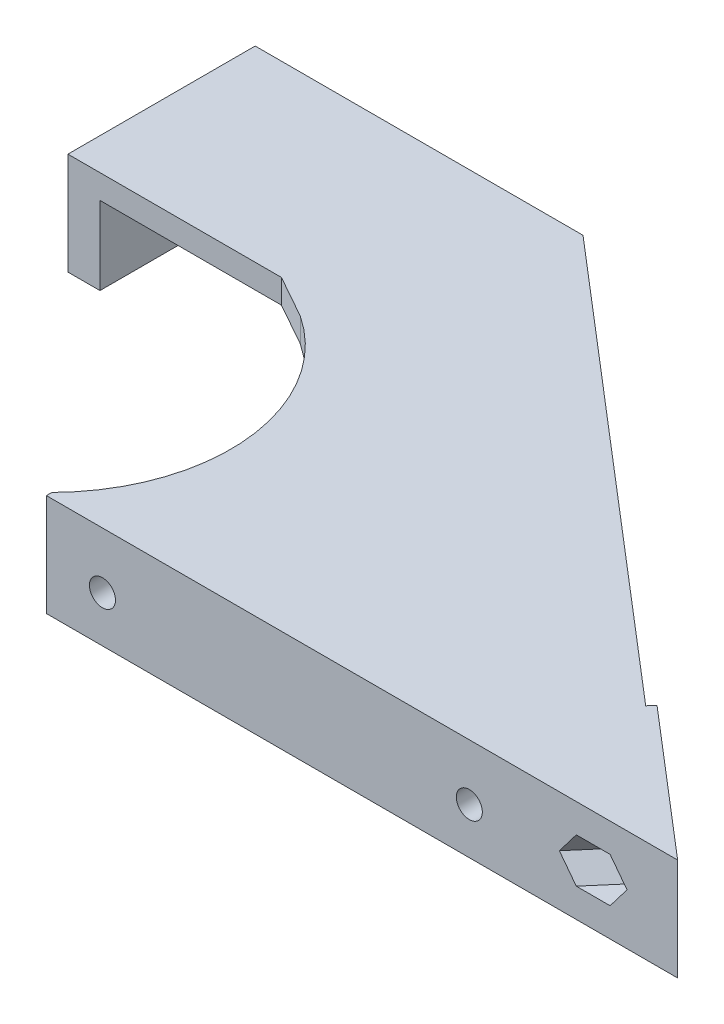
from build123d import *

# Parameters (mm, degrees)
SALIENTE_EXTRUIR1_DEPTH     = 12.75
CORTAR_EXTRUIR1_REACH       = 31.62
CROQUIS2_R                  = 1.625
CROQUIS3_R                  = 22.5
CORTAR_EXTRUIR2_DEPTH       = 13.75
SALIENTE_EXTRUIR2_DEPTH     = 3
SALIENTE_EXTRUIR3_DEPTH     = 9.75
CROQUIS6_R                  = 1.625
CORTAR_EXTRUIR3_DEPTH       = 10
CORTAR_EXTRUIR4_START       = -2
CORTAR_EXTRUIR4_DEPTH       = 10
CORTAR_EXTRUIR5_START       = -2
CORTAR_EXTRUIR5_DEPTH       = 10
CORTAR_EXTRUIR6_DEPTH       = 2
CORTAR_EXTRUIR7_REACH       = 37.25
CROQUIS10_R                 = 1.625
CORTAR_EXTRUIR8_DEPTH       = 2
CROQUIS12_W                 = 92.508691999
CROQUIS12_H                 = 24.255818813
CORTAR_EXTRUIR9_DEPTH       = 1
CORTAR_EXTRUIR9_DEPTH_BACK  = 36.25
SALIENTE_EXTRUIR4_DEPTH     = 12.75
CORTAR_EXTRUIR10_START      = -9.75
CORTAR_EXTRUIR10_DEPTH      = 9.75
CROQUIS16_W                 = 76.692813467
CROQUIS16_H                 = 12.75
CORTAR_EXTRUIR11_DEPTH      = 1
CROQUIS17_W                 = 40.657498706
CROQUIS17_H                 = 22.934549925
CORTAR_EXTRUIR12_DEPTH      = 1
CORTAR_EXTRUIR12_DEPTH_BACK = 13.75
SALIENTE_EXTRUIR5_REACH     = 14.75
CROQUIS18_W                 = 34.9120451
CROQUIS18_H                 = 3.951156815
CROQUIS20_R                 = 1.625
CORTAR_EXTRUIR14_DEPTH      = 10
CORTAR_EXTRUIR15_DEPTH      = 2
CROQUIS22_R                 = 1.625
CORTAR_EXTRUIR16_DEPTH      = 10
CORTAR_EXTRUIR17_DEPTH      = 2
SALIENTE_EXTRUIR6_DEPTH     = 12.75
CORTAR_EXTRUIR18_DEPTH      = 2
CROQUIS28_R                 = 1.625
SALIENTE_EXTRUIR7_DEPTH     = 1
CORTAR_EXTRUIR19_REACH      = 110.346
CROQUIS29_R                 = 1.993280097
CORTAR_EXTRUIR20_DEPTH      = 2
SALIENTE_EXTRUIR8_DEPTH     = 12.75
SALIENTE_EXTRUIR9_START     = -2.904645
SALIENTE_EXTRUIR9_DEPTH     = 5
SALIENTE_EXTRUIR10_REACH    = 76.413
CORTAR_EXTRUIR21_START      = -9.75
CORTAR_EXTRUIR21_DEPTH      = 9.75
CROQUIS36_R                 = 1.625
CORTAR_EXTRUIR22_DEPTH      = 15
CORTAR_EXTRUIR23_DEPTH      = 2
CORTAR_EXTRUIR24_START      = -2
CORTAR_EXTRUIR24_DEPTH      = 73.413335578
CROQUIS19_W                 = 120.448667976
CROQUIS19_H                 = 32.886651308
CORTAR_EXTRUIR13_DEPTH      = 1
CORTAR_EXTRUIR13_DEPTH_BACK = 62.623336743


with BuildPart() as part:
    # Croquis1 → Saliente-Extruir1 (new body)
    with BuildSketch(Plane(origin=(0, 0, 0), x_dir=(1, 0, 0), z_dir=(0, 1, 0))):
        Polygon((0, 0), (72.78319995, 0), (38.224450787, 29.62043043), (35.621353918, 26.5833452), (60.803074847, 5), (0, 5), align=None)
    extrude(amount=SALIENTE_EXTRUIR1_DEPTH)

    # Croquis2 → Cortar-Extruir1 (cut, up to next)
    with BuildSketch(Plane.XY, mode=Mode.PRIVATE) as cortar_extruir1_sk1:
        with Locations((52.78319995, 5.75)):
            Circle(CROQUIS2_R)
    cortar_extruir1_tool1 = extrude(cortar_extruir1_sk1.sketch, amount=-CORTAR_EXTRUIR1_REACH, mode=Mode.PRIVATE) & part.part
    add(cortar_extruir1_tool1.solids().sort_by_distance((52.7832, 5.75, 0))[0], mode=Mode.SUBTRACT)
    # Croquis2 → Cortar-Extruir1 (cut, up to next)
    with BuildSketch(Plane.XY, mode=Mode.PRIVATE) as cortar_extruir1_sk2:
        with Locations((6.99999995, 5.75)):
            Circle(CROQUIS2_R)
    cortar_extruir1_tool2 = extrude(cortar_extruir1_sk2.sketch, amount=-CORTAR_EXTRUIR1_REACH, mode=Mode.PRIVATE) & part.part
    add(cortar_extruir1_tool2.solids().sort_by_distance((7, 5.75, 0))[0], mode=Mode.SUBTRACT)

    # Croquis3 → Cortar-Extruir2 (cut, through all)
    with BuildSketch(Plane(origin=(0, 12.75, 0), x_dir=(1, 0, 0), z_dir=(0, 1, 0))):
        with Locations((-16, 16.5)):
            Circle(CROQUIS3_R)
    extrude(amount=-CORTAR_EXTRUIR2_DEPTH, mode=Mode.SUBTRACT)

    # Croquis4 → Saliente-Extruir2 (add)
    with BuildSketch(Plane(origin=(0, 12.75, 0), x_dir=(1, 0, 0), z_dir=(0, 1, 0))):
        with BuildLine():
            Line((38.224450787, 29.62043043), (31.656319269, 35.25))
            Line((31.656319269, 35.25), (-3.562657036, 35.25))
            ThreePointArc((-3.562657036, 35.25), (5.936291456, 21.504909307), (3.339079606, 5))
            Line((3.339079606, 5), (60.803074847, 5))
            Line((60.803074847, 5), (35.621353918, 26.5833452))
            Line((35.621353918, 26.5833452), (38.224450787, 29.62043043))
        make_face()
    extrude(amount=-SALIENTE_EXTRUIR2_DEPTH)

    # Croquis5 → Saliente-Extruir3 (add)
    with BuildSketch(Plane.XZ.offset(-9.75)):
        with BuildLine():
            Line((-3.562657036, -35.25), (31.656319269, -35.25))
            Line((31.656319269, -35.25), (38.224450787, -29.62043043))
            Line((38.224450787, -29.62043043), (35.621353918, -26.5833452))
            Line((35.621353918, -26.5833452), (30.17667434, -31.25))
            Line((30.17667434, -31.25), (0.990806338, -31.25))
            ThreePointArc((0.990806338, -31.25), (-1.15062315, -33.404023402), (-3.562657036, -35.25))
        make_face()
    extrude(amount=SALIENTE_EXTRUIR3_DEPTH)

    # Croquis6 → Cortar-Extruir3 (cut)
    with BuildSketch(Plane(origin=(30.824200619, 0, -35.963211942), x_dir=(-0.759271307, 0, -0.650774217), z_dir=(0.650774217, 0, -0.759271307))):
        with Locations((-47.262195378, 6.375)):
            Circle(CROQUIS6_R)
        with Locations((-16.095943758, 6.375)):
            Circle(CROQUIS6_R)
    extrude(amount=-CORTAR_EXTRUIR3_DEPTH, mode=Mode.SUBTRACT)

    # Croquis7 → Cortar-Extruir4 (cut)
    with BuildSketch(Plane(origin=(28.22110375, 0, -32.926126712), x_dir=(0.759271307, 0, 0.650774217), z_dir=(-0.650774217, 0, 0.759271307)).offset(CORTAR_EXTRUIR4_START)):
        Polygon((48.849908618, 3.625), (50.437621859, 6.375), (48.849908618, 9.125), (45.674482138, 9.125), (44.086768898, 6.375), (45.674482138, 3.625), align=None)
    extrude(amount=CORTAR_EXTRUIR4_DEPTH, mode=Mode.SUBTRACT)

    # Croquis8 → Cortar-Extruir5 (cut)
    with BuildSketch(Plane(origin=(28.22110375, 0, -32.926126712), x_dir=(0.759271307, 0, 0.650774217), z_dir=(-0.650774217, 0, 0.759271307)).offset(CORTAR_EXTRUIR5_START)):
        Polygon((17.683656999, 3.625), (19.271370239, 6.375), (17.683656999, 9.125), (14.508230518, 9.125), (12.920517278, 6.375), (14.508230518, 3.625), align=None)
    extrude(amount=CORTAR_EXTRUIR5_DEPTH, mode=Mode.SUBTRACT)

    # Croquis9 → Cortar-Extruir6 (cut)
    with BuildSketch(Plane(origin=(0, 0, -5), x_dir=(-1, 0, 0), z_dir=(0, 0, -1))):
        Polygon((-5.41228671, 3), (-3.824573469, 5.75), (-5.41228671, 8.5), (-8.58771319, 8.5), (-10.175426431, 5.75), (-8.58771319, 3), align=None)
        Polygon((-51.19548671, 3), (-49.607773469, 5.75), (-51.19548671, 8.5), (-54.37091319, 8.5), (-55.958626431, 5.75), (-54.37091319, 3), align=None)
    extrude(amount=-CORTAR_EXTRUIR6_DEPTH, mode=Mode.SUBTRACT)

    # Croquis10 → Cortar-Extruir7 (cut, up to next)
    with BuildSketch(Plane(origin=(0, 0, -35.25), x_dir=(-1, 0, 0), z_dir=(0, 0, -1)), mode=Mode.PRIVATE) as cortar_extruir7_sk1:
        with Locations((-21.656319269, 6.375)):
            Circle(CROQUIS10_R)
    cortar_extruir7_tool1 = extrude(cortar_extruir7_sk1.sketch, amount=-CORTAR_EXTRUIR7_REACH, mode=Mode.PRIVATE) & part.part
    add(cortar_extruir7_tool1.solids().sort_by_distance((21.656319, 6.375, -35.25))[0], mode=Mode.SUBTRACT)

    # Croquis11 → Cortar-Extruir8 (cut)
    with BuildSketch(Plane.XY.offset(-31.25)):
        Polygon((23.24403251, 3.625), (24.83174575, 6.375), (23.24403251, 9.125), (20.068606029, 9.125), (18.480892789, 6.375), (20.068606029, 3.625), align=None)
    extrude(amount=-CORTAR_EXTRUIR8_DEPTH, mode=Mode.SUBTRACT)

    # Simetría1: part across plane


with BuildPart() as part_1:
    add(part.part)
    add(part.part.mirror(Plane.ZX))

    # Croquis12 → Cortar-Extruir9 (cut, two sides)
    with BuildSketch(Plane(origin=(0, 0, -35.25), x_dir=(-1, 0, 0), z_dir=(0, 0, -1))) as cortar_extruir9_sk:
        with Locations((-33.077560565, 12.127909407)):
            Rectangle(CROQUIS12_W, CROQUIS12_H)
    extrude(amount=CORTAR_EXTRUIR9_DEPTH, mode=Mode.SUBTRACT)
    extrude(cortar_extruir9_sk.sketch, amount=-CORTAR_EXTRUIR9_DEPTH_BACK, mode=Mode.SUBTRACT)

    # Croquis13 → Saliente-Extruir4 (add)
    with BuildSketch(Plane.XZ.offset(12.75)):
        Polygon((-35.562657036, -82.38260805), (-35.562657036, -38.25), (-8.913300435, -38.25), (-3.562657036, -35.25), (31.656319269, -35.25), (0.000162281, -62.38260805), align=None)
    extrude(amount=-SALIENTE_EXTRUIR4_DEPTH)

    # Croquis14 → Cortar-Extruir10 (cut)
    with BuildSketch(Plane(origin=(0, 0, 0), x_dir=(1, 0, 0), z_dir=(0, 1, 0)).offset(CORTAR_EXTRUIR10_START)):
        Polygon((30.17667434, 31.25), (0.990806338, 31.25), (-31.562657036, 38.25), (-31.562657036, 75.543902968), (-2.303881466, 59.089203295), align=None)
    extrude(amount=CORTAR_EXTRUIR10_DEPTH, mode=Mode.SUBTRACT)

    # Croquis16 → Cortar-Extruir11 (cut)
    with BuildSketch(Plane(origin=(30.824200619, 0, -35.963211942), x_dir=(-0.759271307, 0, -0.650774217), z_dir=(0.650774217, 0, -0.759271307))):
        with Locations((2.250462975, -6.375)):
            Rectangle(CROQUIS16_W, CROQUIS16_H)
    extrude(amount=-CORTAR_EXTRUIR11_DEPTH, mode=Mode.SUBTRACT)

    # Croquis17 → Cortar-Extruir12 (cut, two sides)
    with BuildSketch(Plane.XZ.offset(12.75)) as cortar_extruir12_sk:
        with Locations((-20.328587072, -73.090611706)):
            Rectangle(CROQUIS17_W, CROQUIS17_H)
    extrude(amount=CORTAR_EXTRUIR12_DEPTH, mode=Mode.SUBTRACT)
    extrude(cortar_extruir12_sk.sketch, amount=-CORTAR_EXTRUIR12_DEPTH_BACK, mode=Mode.SUBTRACT)

    # Croquis18 → Saliente-Extruir5 (add, up to next)
    with BuildSketch(Plane(origin=(0, 0, 0), x_dir=(1, 0, 0), z_dir=(0, 1, 0)), mode=Mode.PRIVATE) as saliente_extruir5_sk1:
        with Locations((-18.106634486, 59.647758336)):
            Rectangle(CROQUIS18_W, CROQUIS18_H)
    saliente_extruir5_tool1 = extrude(saliente_extruir5_sk1.sketch, amount=-SALIENTE_EXTRUIR5_REACH, mode=Mode.PRIVATE) - part_1.part
    add(saliente_extruir5_tool1.solids().sort_by_distance((-18.106634, 0, -59.647758))[0])

    # Croquis20 → Cortar-Extruir14 (cut)
    with BuildSketch(Plane(origin=(30.173426402, 0, -35.203940634), x_dir=(-0.759271307, 0, -0.650774217), z_dir=(0.650774217, 0, -0.759271307))):
        with Locations((25.596869709, -6.375)):
            Circle(CROQUIS20_R)
        with Locations((-16.095943758, -6.375)):
            Circle(CROQUIS20_R)
    extrude(amount=-CORTAR_EXTRUIR14_DEPTH, mode=Mode.SUBTRACT)

    # Croquis21 → Cortar-Extruir15 (cut)
    with BuildSketch(Plane(origin=(28.22110375, 0, -32.926126712), x_dir=(0.759271307, 0, 0.650774217), z_dir=(-0.650774217, 0, 0.759271307))):
        Polygon((-24.009156469, -9.125), (-22.421443229, -6.375), (-24.009156469, -3.625), (-27.184582949, -3.625), (-28.77229619, -6.375), (-27.184582949, -9.125), align=None)
    extrude(amount=-CORTAR_EXTRUIR15_DEPTH, mode=Mode.SUBTRACT)

    # Croquis22 → Cortar-Extruir16 (cut)
    with BuildSketch(Plane(origin=(0, 0, -61.623336743), x_dir=(-1, 0, 0), z_dir=(0, 0, -1))):
        with Locations((18.112657036, -6.375)):
            Circle(CROQUIS22_R)
    extrude(amount=-CORTAR_EXTRUIR16_DEPTH, mode=Mode.SUBTRACT)

    # Croquis23 → Cortar-Extruir17 (cut)
    with BuildSketch(Plane.XY.offset(-57.672179928)):
        Polygon((-16.524943796, -9.125), (-14.937230556, -6.375), (-16.524943796, -3.625), (-19.700370276, -3.625), (-21.288083517, -6.375), (-19.700370276, -9.125), align=None)
    extrude(amount=-CORTAR_EXTRUIR17_DEPTH, mode=Mode.SUBTRACT)

    # Croquis26 → Saliente-Extruir6 (add)
    with BuildSketch(Plane(origin=(0, 0, 0), x_dir=(1, 0, 0), z_dir=(0, 1, 0))):
        Polygon((60.803074847, 5), (-2.287792345, 59.07541325), (-2.938566562, 58.316141943), (60.15230063, 4.240728693), align=None)
    extrude(amount=-SALIENTE_EXTRUIR6_DEPTH)

    # Croquis27 → Cortar-Extruir18 (cut)
    with BuildSketch(Plane(origin=(27.570329533, 0, -32.166855405), x_dir=(0.759271307, 0, 0.650774217), z_dir=(-0.650774217, 0, 0.759271307))):
        Polygon((-22.421443229, -6.375), (-24.009156469, -3.625), (-27.184582949, -3.625), (-28.77229619, -6.375), (-27.184582949, -9.125), (-24.009156469, -9.125), align=None)
        Polygon((19.271370239, -6.375), (17.683656999, -3.625), (14.508230518, -3.625), (12.920517278, -6.375), (14.508230518, -9.125), (17.683656999, -9.125), align=None)
    extrude(amount=-CORTAR_EXTRUIR18_DEPTH, mode=Mode.SUBTRACT)

    # Croquis28 → Saliente-Extruir7 (add)
    with BuildSketch(Plane(origin=(29.522652185, 0, -34.444669327), x_dir=(0.759271307, 0, 0.650774217), z_dir=(-0.650774217, 0, 0.759271307))):
        Polygon((-24.009156469, -3.625), (-27.184582949, -3.625), (-28.77229619, -6.375), (-27.184582949, -9.125), (-24.009156469, -9.125), (-22.421443229, -6.375), align=None)
        with Locations((-25.596869709, -6.375)):
            Circle(CROQUIS28_R, mode=Mode.SUBTRACT)
        Polygon((17.683656999, -3.625), (14.508230518, -3.625), (12.920517278, -6.375), (14.508230518, -9.125), (17.683656999, -9.125), (19.271370239, -6.375), align=None)
        with Locations((16.095943758, -6.375)):
            Circle(CROQUIS28_R, mode=Mode.SUBTRACT)
    extrude(amount=SALIENTE_EXTRUIR7_DEPTH)

    # Croquis29 → Cortar-Extruir19 (cut, up to next)
    with BuildSketch(Plane.ZY.offset(35.562657036), mode=Mode.PRIVATE) as cortar_extruir19_sk1:
        with Locations((-51.623336743, -6.375)):
            Circle(CROQUIS29_R)
    cortar_extruir19_tool1 = extrude(cortar_extruir19_sk1.sketch, amount=-CORTAR_EXTRUIR19_REACH, mode=Mode.PRIVATE) & part_1.part
    add(cortar_extruir19_tool1.solids().sort_by_distance((-35.562657, -6.375, -51.623337))[0], mode=Mode.SUBTRACT)

    # Croquis30 → Cortar-Extruir20 (cut)
    with BuildSketch(Plane(origin=(-31.562657036, 0, 0), x_dir=(0, 0, -1), z_dir=(1, 0, 0))):
        Polygon((53.238108484, -9.125), (54.825821725, -6.375), (53.238108484, -3.625), (50.062682004, -3.625), (48.474968763, -6.375), (50.062682004, -9.125), align=None)
    extrude(amount=-CORTAR_EXTRUIR20_DEPTH, mode=Mode.SUBTRACT)

    # Croquis32 → Saliente-Extruir8 (add)
    with BuildSketch(Plane.XZ.offset(12.75)):
        Polygon((-0.650611936, -61.623336743), (5.349388064, -61.623336743), (60.1210833, -14.678316233), (60.771857517, -15.43758754), (78.78319995, 0), (72.78319995, 0), (58.230815026, -12.472902396), (57.580040809, -11.713631088), align=None)
    extrude(amount=-SALIENTE_EXTRUIR8_DEPTH)

    # Croquis33 → Saliente-Extruir9 (add)
    with BuildSketch(Plane(origin=(32.714468893, 0, -38.168625779), x_dir=(-0.759271307, 0, -0.650774217), z_dir=(0.650774217, 0, -0.759271307)).offset(SALIENTE_EXTRUIR9_START)):
        Polygon((-14.508230518, -3.625), (-17.683656999, -3.625), (-19.271370239, -6.375), (-17.683656999, -9.125), (-14.508230518, -9.125), (-12.920517278, -6.375), align=None)
        Polygon((27.184582949, -3.625), (24.009156469, -3.625), (22.421443229, -6.375), (24.009156469, -9.125), (27.184582949, -9.125), (28.77229619, -6.375), align=None)
    extrude(amount=-SALIENTE_EXTRUIR9_DEPTH)

    # Saliente-Extruir10: up to this face of the body (flat: up to its plane)
    saliente_extruir10_end = Plane(part_1.part.faces().sort_by_distance((38.729797406, -6.385876659, 0))[0])
    # Croquis34 → Saliente-Extruir10 (add, up to the picked face)
    with BuildSketch(Plane(origin=(33.36524311, 0, -38.927897086), x_dir=(-0.759271307, 0, -0.650774217), z_dir=(0.650774217, 0, -0.759271307)), mode=Mode.PRIVATE) as saliente_extruir10_sk1:
        Polygon((-45.674482138, -3.625), (-48.849908618, -3.625), (-50.437621859, -6.375), (-48.849908618, -9.125), (-45.674482138, -9.125), (-44.086768898, -6.375), align=None)
    saliente_extruir10_tool1 = split(extrude(saliente_extruir10_sk1.sketch, amount=-SALIENTE_EXTRUIR10_REACH, mode=Mode.PRIVATE), bisect_by=saliente_extruir10_end, keep=Keep.BOTH, mode=Mode.PRIVATE)
    add(saliente_extruir10_tool1.solids().sort_by_distance((69.250072, -6.375, -8.170879))[0])

    # Croquis35 → Cortar-Extruir21 (cut)
    with BuildSketch(Plane(origin=(0, 0, 0), x_dir=(1, 0, 0), z_dir=(0, 1, 0)).offset(CORTAR_EXTRUIR21_START)):
        Polygon((-2.187243188, 57.672179928), (3.812756812, 57.672179928), (65.266443595, 5), (59.266443595, 5), align=None)
    extrude(amount=CORTAR_EXTRUIR21_DEPTH, mode=Mode.SUBTRACT)

    # Croquis36 → Cortar-Extruir22 (cut)
    with BuildSketch(Plane(origin=(33.36524311, 0, -38.927897086), x_dir=(-0.759271307, 0, -0.650774217), z_dir=(0.650774217, 0, -0.759271307))):
        with Locations((-51.817823222, -6.375)):
            Circle(CROQUIS36_R)
        with Locations((-20.647823222, -6.375)):
            Circle(CROQUIS36_R)
        with Locations((21.042176778, -6.375)):
            Circle(CROQUIS36_R)
    extrude(amount=-CORTAR_EXTRUIR22_DEPTH, mode=Mode.SUBTRACT)

    # Croquis38 → Cortar-Extruir23 (cut)
    with BuildSketch(Plane(origin=(30.111372024, 0, -35.131540549), x_dir=(0.759271307, 0, 0.650774217), z_dir=(-0.650774217, 0, 0.759271307))):
        Polygon((-19.440029781, -9.15), (-17.837882784, -6.375), (-19.440029781, -3.6), (-22.644323775, -3.6), (-24.246470772, -6.375), (-22.644323775, -9.15), align=None)
        Polygon((22.249970219, -9.15), (23.852117216, -6.375), (22.249970219, -3.6), (19.045676225, -3.6), (17.443529228, -6.375), (19.045676225, -9.15), align=None)
    extrude(amount=-CORTAR_EXTRUIR23_DEPTH, mode=Mode.SUBTRACT)

    # Croquis39 → Cortar-Extruir24 (cut, through all)
    with BuildSketch(Plane(origin=(33.36524311, 0, -38.927897086), x_dir=(-0.759271307, 0, -0.650774217), z_dir=(0.650774217, 0, -0.759271307)).offset(CORTAR_EXTRUIR24_START)):
        Polygon((-50.215676225, -9.15), (-48.613529228, -6.375), (-50.215676225, -3.6), (-53.419970219, -3.6), (-55.022117216, -6.375), (-53.419970219, -9.15), align=None)
    extrude(amount=-CORTAR_EXTRUIR24_DEPTH, mode=Mode.SUBTRACT)

    # Simetría2: part across face


with BuildPart() as part_2:
    add(part_1.part)
    add(part_1.part.mirror(Plane(origin=(15.909867024, -12.75, -29.216307939), x_dir=(0, 0, 1), z_dir=(0, -1, 0))))

    # Croquis19 → Cortar-Extruir13 (cut, two sides)
    with BuildSketch(Plane(origin=(0, 0, -61.623336743), x_dir=(-1, 0, 0), z_dir=(0, 0, -1))) as cortar_extruir13_sk:
        with Locations((-18.558865962, 3.693325654)):
            Rectangle(CROQUIS19_W, CROQUIS19_H)
    extrude(amount=CORTAR_EXTRUIR13_DEPTH, mode=Mode.SUBTRACT)
    extrude(cortar_extruir13_sk.sketch, amount=-CORTAR_EXTRUIR13_DEPTH_BACK, mode=Mode.SUBTRACT)


solid = part_2.part
